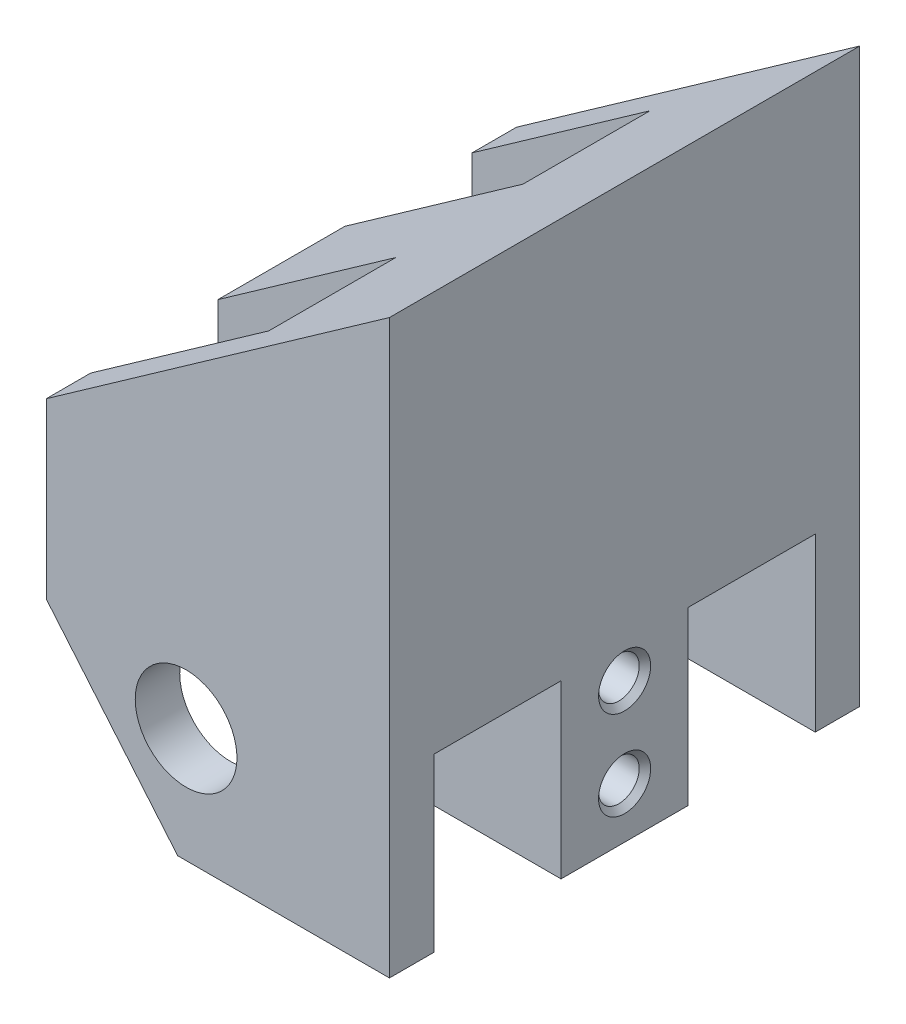
from build123d import *

# Parameters (mm, degrees)
BOSS_EXTRUDE1_DEPTH             = 18.5
SKETCH2_R                       = 2
CUT_EXTRUDE1_DEPTH              = 26.520703612
SKETCH2_3_R                     = 1.5
CUT_EXTRUDE2_DEPTH              = 11
CUT_EXTRUDE3_DEPTH              = 26.520703612
CUT_EXTRUDE4_DEPTH              = 25.032044873
SKETCH7_W                       = 5
SKETCH7_H                       = 6.75
CUT_EXTRUDE5_DEPTH              = 27.586510204
M2X0_4_TAPPED_HOLE1_D           = 1.6
M2X0_4_TAPPED_HOLE1_DEPTH       = 5
M2X0_4_TAPPED_HOLE1_CSINK_D     = 2.05
M2X0_4_TAPPED_HOLE1_CSINK_ANGLE = 90
M2X0_4_TAPPED_HOLE1_TIP         = 0.480688495
SKETCH11_W                      = 7
SKETCH11_H                      = 5
CUT_EXTRUDE6_DEPTH              = 26.362554209


with BuildPart() as part:
    # Sketch1 → Boss-Extrude1 (new body)
    with BuildSketch(Plane.XY):
        Polygon((-7.276445285, -10.518598852), (2.223554715, -16.00342641), (6.223554715, -16.00342641), (6.223554715, 8.99657359), (-7.276445285, -0.518598852), align=None)
    extrude(amount=BOSS_EXTRUDE1_DEPTH)

    # Sketch2 → Cut-Extrude1 (cut, through all)
    with BuildSketch(Plane(origin=(0, 0, 0), x_dir=(-1, 0, 0), z_dir=(0, 0, -1))):
        with Locations((1.776445285, -9.00342641)):
            Circle(SKETCH2_R)
    extrude(amount=-CUT_EXTRUDE1_DEPTH, mode=Mode.SUBTRACT)

    # Sketch2_3 → Cut-Extrude2 (cut)
    with BuildSketch(Plane(origin=(0, 0, 0), x_dir=(-1, 0, 0), z_dir=(0, 0, -1))):
        with Locations((-2.223554715, -5.00342641)):
            Circle(SKETCH2_3_R)
    extrude(amount=-CUT_EXTRUDE2_DEPTH, mode=Mode.SUBTRACT)

    # Sketch5 → Cut-Extrude3 (cut, through all)
    with BuildSketch(Plane(origin=(0, 0, 0), x_dir=(-1, 0, 0), z_dir=(0, 0, -1))):
        Polygon((-6.223554715, -13.50342641), (2.106572304, -13.50342641), (-2.223554715, -16.00342641), (-6.223554715, -16.00342641), align=None)
    extrude(amount=-CUT_EXTRUDE3_DEPTH, mode=Mode.SUBTRACT)

    # Sketch6 → Cut-Extrude4 (cut, through all)
    with BuildSketch(Plane(origin=(0, 0, 0), x_dir=(-1, 0, 0), z_dir=(0, 0, -1))):
        Polygon((2.106572304, -13.50342641), (7.276445285, -7.342211711), (7.276445285, -10.518598852), align=None)
    extrude(amount=-CUT_EXTRUDE4_DEPTH, mode=Mode.SUBTRACT)

    # Sketch7 → Cut-Extrude5 (cut, through all)
    with BuildSketch(Plane(origin=(6.223554715, 0, 0), x_dir=(0, 0, -1), z_dir=(1, 0, 0))):
        with Locations((-14.25, -10.12842641)):
            Rectangle(SKETCH7_W, SKETCH7_H)
        with Locations((-4.25, -10.12842641)):
            Rectangle(SKETCH7_W, SKETCH7_H)
    extrude(amount=-CUT_EXTRUDE5_DEPTH, mode=Mode.SUBTRACT)

    # M2x0.4 Tapped Hole1
    with Locations(Plane(origin=(6.223554715, 0, 0), x_dir=(0, 0, -1), z_dir=(1, 0, 0))):
        with Locations((-9.25, -8.00342641), (-9.25, -11.50342641)):
            CounterSinkHole(M2X0_4_TAPPED_HOLE1_D / 2, M2X0_4_TAPPED_HOLE1_CSINK_D / 2, depth=M2X0_4_TAPPED_HOLE1_DEPTH, counter_sink_angle=M2X0_4_TAPPED_HOLE1_CSINK_ANGLE)
            with Locations((0, 0, -(M2X0_4_TAPPED_HOLE1_DEPTH + M2X0_4_TAPPED_HOLE1_TIP / 2))):  # 118° drill point
                Cone(0, M2X0_4_TAPPED_HOLE1_D / 2, M2X0_4_TAPPED_HOLE1_TIP, mode=Mode.SUBTRACT)

    # Sketch11 → Cut-Extrude6 (cut, through all)
    with BuildSketch(Plane.XZ.offset(6.75342641)):
        with Locations((-3.776445285, 14.25)):
            Rectangle(SKETCH11_W, SKETCH11_H)
        with Locations((-3.776445285, 4.25)):
            Rectangle(SKETCH11_W, SKETCH11_H)
    extrude(amount=-CUT_EXTRUDE6_DEPTH, mode=Mode.SUBTRACT)


solid = part.part
